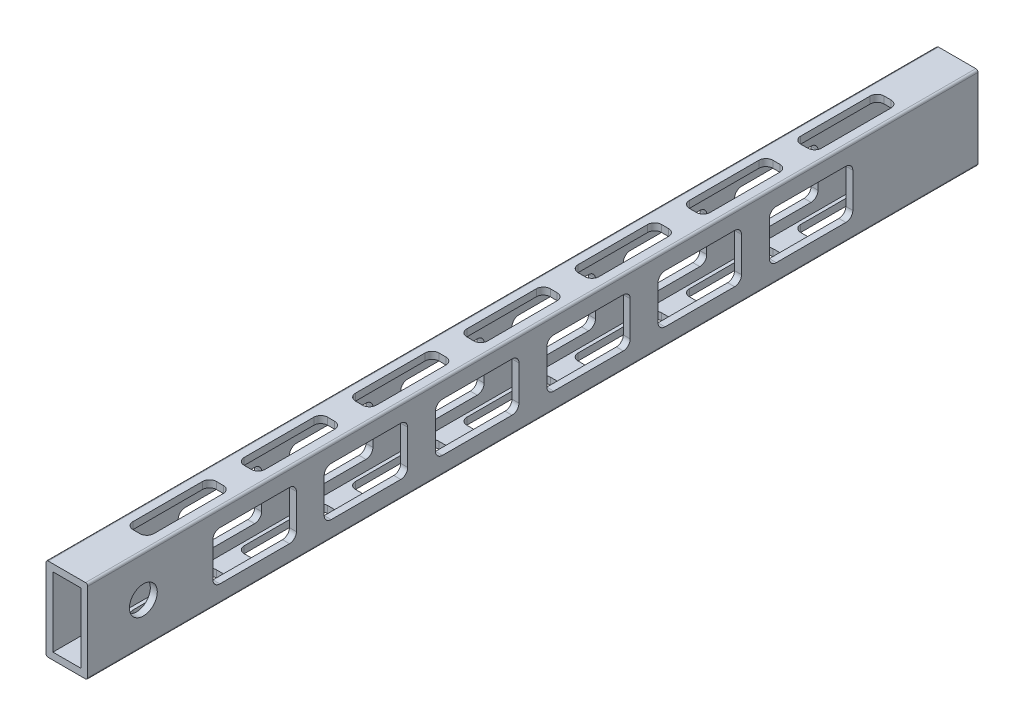
from build123d import *

# Parameters (mm, degrees)
SKETCH1_W               = 12.7
SKETCH1_H               = 31.75
BOSS_EXTRUDE1_DEPTH     = 203.2
CUT_EXTRUDE1_DEPTH      = 207.960323794
CUT_EXTRUDE1_DEPTH_BACK = 207.960323794
CUT_EXTRUDE2_DEPTH      = 205.978157373
CUT_EXTRUDE2_DEPTH_BACK = 205.978157373
SKETCH4_R               = 6.35
CUT_EXTRUDE3_DEPTH      = 205.978157373
CUT_EXTRUDE3_DEPTH_BACK = 205.978157373


with BuildPart() as part:
    # Sketch1 → Boss-Extrude1 (new, symmetric)
    with BuildSketch(Plane.XY):
        with BuildLine():
            Line((-8.525, -19.05), (8.525, -19.05))
            ThreePointArc((8.525, -19.05), (9.232106781, -18.757106781), (9.525, -18.05))
            Line((9.525, -18.05), (9.525, 18.05))
            ThreePointArc((9.525, 18.05), (9.232106781, 18.757106781), (8.525, 19.05))
            Line((8.525, 19.05), (-8.525, 19.05))
            ThreePointArc((-8.525, 19.05), (-9.232106781, 18.757106781), (-9.525, 18.05))
            Line((-9.525, 18.05), (-9.525, -18.05))
            ThreePointArc((-9.525, -18.05), (-9.232106781, -18.757106781), (-8.525, -19.05))
        make_face()
        Rectangle(SKETCH1_W, SKETCH1_H, mode=Mode.SUBTRACT)
    extrude(amount=BOSS_EXTRUDE1_DEPTH, both=True)

    # Sketch2 → Cut-Extrude1 (cut, two sides)
    with BuildSketch(Plane(origin=(0, 19.05, 0), x_dir=(1, 0, 0), z_dir=(0, 1, 0))) as cut_extrude1_sk:
        with BuildLine():
            Line((-4.7625, -117.475), (-4.7625, -85.725))
            ThreePointArc((-4.7625, -85.725), (-3.83256403, -83.47993597), (-1.5875, -82.55))
            Line((-1.5875, -82.55), (1.5875, -82.55))
            ThreePointArc((1.5875, -82.55), (3.83256403, -83.47993597), (4.7625, -85.725))
            Line((4.7625, -85.725), (4.7625, -117.475))
            ThreePointArc((4.7625, -117.475), (3.83256403, -119.72006403), (1.5875, -120.65))
            Line((1.5875, -120.65), (-1.5875, -120.65))
            ThreePointArc((-1.5875, -120.65), (-3.83256403, -119.72006403), (-4.7625, -117.475))
        make_face()
        with BuildLine():
            Line((-1.5875, -171.45), (1.5875, -171.45))
            ThreePointArc((1.5875, -171.45), (3.83256403, -170.52006403), (4.7625, -168.275))
            Line((4.7625, -168.275), (4.7625, -136.525))
            ThreePointArc((4.7625, -136.525), (3.83256403, -134.27993597), (1.5875, -133.35))
            Line((1.5875, -133.35), (-1.5875, -133.35))
            ThreePointArc((-1.5875, -133.35), (-3.83256403, -134.27993597), (-4.7625, -136.525))
            Line((-4.7625, -136.525), (-4.7625, -168.275))
            ThreePointArc((-4.7625, -168.275), (-3.83256403, -170.52006403), (-1.5875, -171.45))
        make_face()
        with BuildLine():
            Line((-4.7625, -66.675), (-4.7625, -34.925))
            ThreePointArc((-4.7625, -34.925), (-3.83256403, -32.67993597), (-1.5875, -31.75))
            Line((-1.5875, -31.75), (1.5875, -31.75))
            ThreePointArc((1.5875, -31.75), (3.83256403, -32.67993597), (4.7625, -34.925))
            Line((4.7625, -34.925), (4.7625, -66.675))
            ThreePointArc((4.7625, -66.675), (3.83256403, -68.92006403), (1.5875, -69.85))
            Line((1.5875, -69.85), (-1.5875, -69.85))
            ThreePointArc((-1.5875, -69.85), (-3.83256403, -68.92006403), (-4.7625, -66.675))
        make_face()
        with BuildLine():
            Line((-4.7625, -15.875), (-4.7625, 15.875))
            ThreePointArc((-4.7625, 15.875), (-3.83256403, 18.12006403), (-1.5875, 19.05))
            Line((-1.5875, 19.05), (1.5875, 19.05))
            ThreePointArc((1.5875, 19.05), (3.83256403, 18.12006403), (4.7625, 15.875))
            Line((4.7625, 15.875), (4.7625, -15.875))
            ThreePointArc((4.7625, -15.875), (3.83256403, -18.12006403), (1.5875, -19.05))
            Line((1.5875, -19.05), (-1.5875, -19.05))
            ThreePointArc((-1.5875, -19.05), (-3.83256403, -18.12006403), (-4.7625, -15.875))
        make_face()
        with BuildLine():
            Line((-4.7625, 34.925), (-4.7625, 66.675))
            ThreePointArc((-4.7625, 66.675), (-3.83256403, 68.92006403), (-1.5875, 69.85))
            Line((-1.5875, 69.85), (1.5875, 69.85))
            ThreePointArc((1.5875, 69.85), (3.83256403, 68.92006403), (4.7625, 66.675))
            Line((4.7625, 66.675), (4.7625, 34.925))
            ThreePointArc((4.7625, 34.925), (3.83256403, 32.67993597), (1.5875, 31.75))
            Line((1.5875, 31.75), (-1.5875, 31.75))
            ThreePointArc((-1.5875, 31.75), (-3.83256403, 32.67993597), (-4.7625, 34.925))
        make_face()
        with BuildLine():
            Line((-4.7625, 85.725), (-4.7625, 117.475))
            ThreePointArc((-4.7625, 117.475), (-3.83256403, 119.72006403), (-1.5875, 120.65))
            Line((-1.5875, 120.65), (1.5875, 120.65))
            ThreePointArc((1.5875, 120.65), (3.83256403, 119.72006403), (4.7625, 117.475))
            Line((4.7625, 117.475), (4.7625, 85.725))
            ThreePointArc((4.7625, 85.725), (3.83256403, 83.47993597), (1.5875, 82.55))
            Line((1.5875, 82.55), (-1.5875, 82.55))
            ThreePointArc((-1.5875, 82.55), (-3.83256403, 83.47993597), (-4.7625, 85.725))
        make_face()
        with BuildLine():
            Line((-4.7625, 136.525), (-4.7625, 168.275))
            ThreePointArc((-4.7625, 168.275), (-3.83256403, 170.52006403), (-1.5875, 171.45))
            Line((-1.5875, 171.45), (1.5875, 171.45))
            ThreePointArc((1.5875, 171.45), (3.83256403, 170.52006403), (4.7625, 168.275))
            Line((4.7625, 168.275), (4.7625, 136.525))
            ThreePointArc((4.7625, 136.525), (3.83256403, 134.27993597), (1.5875, 133.35))
            Line((1.5875, 133.35), (-1.5875, 133.35))
            ThreePointArc((-1.5875, 133.35), (-3.83256403, 134.27993597), (-4.7625, 136.525))
        make_face()
    extrude(amount=CUT_EXTRUDE1_DEPTH, mode=Mode.SUBTRACT)
    extrude(cut_extrude1_sk.sketch, amount=-CUT_EXTRUDE1_DEPTH_BACK, mode=Mode.SUBTRACT)

    # Sketch3 → Cut-Extrude2 (cut, two sides)
    with BuildSketch(Plane(origin=(9.525, 0, 0), x_dir=(0, 0, -1), z_dir=(1, 0, 0))) as cut_extrude2_sk:
        with BuildLine():
            Line((-95.25, -7.9375), (-95.25, 7.9375))
            ThreePointArc((-95.25, 7.9375), (-94.32006403, 10.18256403), (-92.075, 11.1125))
            Line((-92.075, 11.1125), (-60.325, 11.1125))
            ThreePointArc((-60.325, 11.1125), (-58.07993597, 10.18256403), (-57.15, 7.9375))
            Line((-57.15, 7.9375), (-57.15, -7.9375))
            ThreePointArc((-57.15, -7.9375), (-58.07993597, -10.18256403), (-60.325, -11.1125))
            Line((-60.325, -11.1125), (-92.075, -11.1125))
            ThreePointArc((-92.075, -11.1125), (-94.32006403, -10.18256403), (-95.25, -7.9375))
        make_face()
        with BuildLine():
            Line((-142.875, -11.1125), (-111.125, -11.1125))
            ThreePointArc((-111.125, -11.1125), (-108.87993597, -10.18256403), (-107.95, -7.9375))
            Line((-107.95, -7.9375), (-107.95, 7.9375))
            ThreePointArc((-107.95, 7.9375), (-108.87993597, 10.18256403), (-111.125, 11.1125))
            Line((-111.125, 11.1125), (-142.875, 11.1125))
            ThreePointArc((-142.875, 11.1125), (-145.12006403, 10.18256403), (-146.05, 7.9375))
            Line((-146.05, 7.9375), (-146.05, -7.9375))
            ThreePointArc((-146.05, -7.9375), (-145.12006403, -10.18256403), (-142.875, -11.1125))
        make_face()
        with BuildLine():
            Line((-44.45, -7.9375), (-44.45, 7.9375))
            ThreePointArc((-44.45, 7.9375), (-43.52006403, 10.18256403), (-41.275, 11.1125))
            Line((-41.275, 11.1125), (-9.525, 11.1125))
            ThreePointArc((-9.525, 11.1125), (-7.27993597, 10.18256403), (-6.35, 7.9375))
            Line((-6.35, 7.9375), (-6.35, -7.9375))
            ThreePointArc((-6.35, -7.9375), (-7.27993597, -10.18256403), (-9.525, -11.1125))
            Line((-9.525, -11.1125), (-41.275, -11.1125))
            ThreePointArc((-41.275, -11.1125), (-43.52006403, -10.18256403), (-44.45, -7.9375))
        make_face()
        with BuildLine():
            Line((6.35, -7.9375), (6.35, 7.9375))
            ThreePointArc((6.35, 7.9375), (7.27993597, 10.18256403), (9.525, 11.1125))
            Line((9.525, 11.1125), (41.275, 11.1125))
            ThreePointArc((41.275, 11.1125), (43.52006403, 10.18256403), (44.45, 7.9375))
            Line((44.45, 7.9375), (44.45, -7.9375))
            ThreePointArc((44.45, -7.9375), (43.52006403, -10.18256403), (41.275, -11.1125))
            Line((41.275, -11.1125), (9.525, -11.1125))
            ThreePointArc((9.525, -11.1125), (7.27993597, -10.18256403), (6.35, -7.9375))
        make_face()
        with BuildLine():
            Line((57.15, -7.9375), (57.15, 7.9375))
            ThreePointArc((57.15, 7.9375), (58.07993597, 10.18256403), (60.325, 11.1125))
            Line((60.325, 11.1125), (92.075, 11.1125))
            ThreePointArc((92.075, 11.1125), (94.32006403, 10.18256403), (95.25, 7.9375))
            Line((95.25, 7.9375), (95.25, -7.9375))
            ThreePointArc((95.25, -7.9375), (94.32006403, -10.18256403), (92.075, -11.1125))
            Line((92.075, -11.1125), (60.325, -11.1125))
            ThreePointArc((60.325, -11.1125), (58.07993597, -10.18256403), (57.15, -7.9375))
        make_face()
        with BuildLine():
            Line((107.95, -7.9375), (107.95, 7.9375))
            ThreePointArc((107.95, 7.9375), (108.87993597, 10.18256403), (111.125, 11.1125))
            Line((111.125, 11.1125), (142.875, 11.1125))
            ThreePointArc((142.875, 11.1125), (145.12006403, 10.18256403), (146.05, 7.9375))
            Line((146.05, 7.9375), (146.05, -7.9375))
            ThreePointArc((146.05, -7.9375), (145.12006403, -10.18256403), (142.875, -11.1125))
            Line((142.875, -11.1125), (111.125, -11.1125))
            ThreePointArc((111.125, -11.1125), (108.87993597, -10.18256403), (107.95, -7.9375))
        make_face()
    extrude(amount=CUT_EXTRUDE2_DEPTH, mode=Mode.SUBTRACT)
    extrude(cut_extrude2_sk.sketch, amount=-CUT_EXTRUDE2_DEPTH_BACK, mode=Mode.SUBTRACT)

    # Sketch4 → Cut-Extrude3 (cut, two sides)
    with BuildSketch(Plane(origin=(9.525, 0, 0), x_dir=(0, 0, -1), z_dir=(1, 0, 0))) as cut_extrude3_sk:
        with Locations((-177.8, 0)):
            Circle(SKETCH4_R)
    extrude(amount=CUT_EXTRUDE3_DEPTH, mode=Mode.SUBTRACT)
    extrude(cut_extrude3_sk.sketch, amount=-CUT_EXTRUDE3_DEPTH_BACK, mode=Mode.SUBTRACT)


solid = part.part
